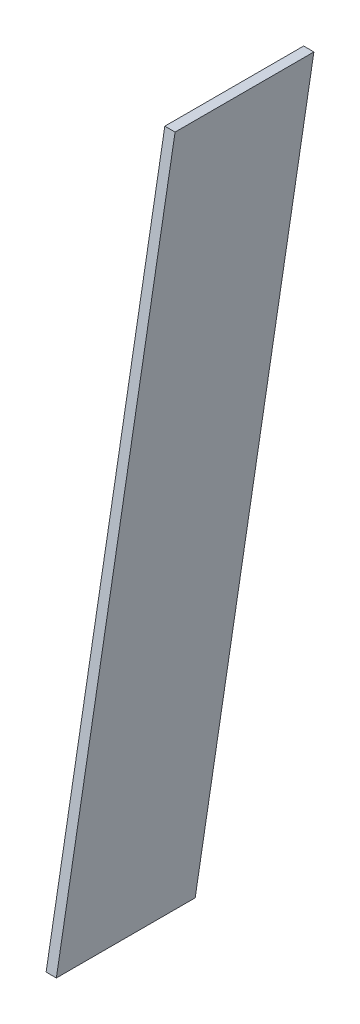
from build123d import *

# Parameters (mm, degrees)
BOSS_EXTRUDE1_DEPTH = 15


with BuildPart() as part:
    # Sketch1 → Boss-Extrude1 (new body, symmetric)
    with BuildSketch(Plane(origin=(0, 0, 0), x_dir=(0, 0, -1), z_dir=(1, 0, 0))):
        Polygon((0, 456), (-347.296355334, -1513.615506024), (-753.467000088, -1513.615506024), (-406.170644754, 456), align=None)
    extrude(amount=BOSS_EXTRUDE1_DEPTH, both=True)


solid = part.part
